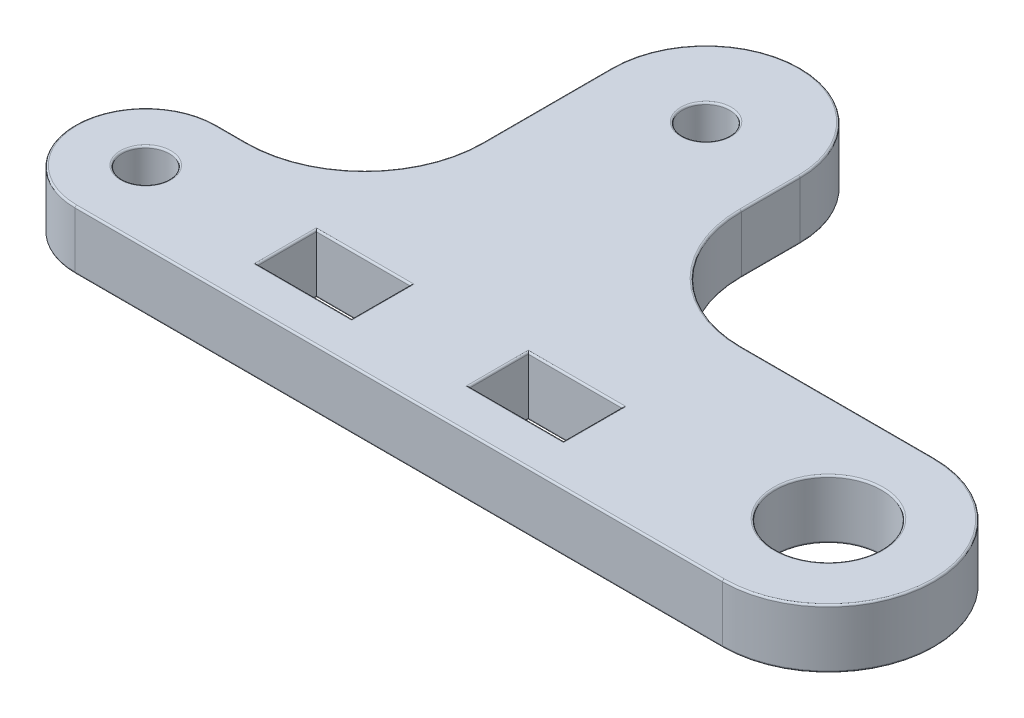
from build123d import *

# Parameters (mm, degrees)
SKETCH2_R           = 2
SKETCH2_R_2         = 4.5
SKETCH2_W           = 8
SKETCH2_H           = 5
BOSS_EXTRUDE1_DEPTH = 2.5
FILLET1_R           = 0.15


with BuildPart() as part:
    # Sketch2 → Boss-Extrude1 (new body, symmetric)
    with BuildSketch(Plane(origin=(0, 0, 0), x_dir=(1, 0, 0), z_dir=(0, 1, 0))):
        with BuildLine():
            Line((-27.5, 0), (27.5, 0))
            ThreePointArc((27.5, 0), (36.5, 9), (27.5, 18))
            Line((27.5, 18), (11.1, 18))
            ThreePointArc((11.1, 18), (4.028932188, 20.928932188), (1.1, 28))
            Line((1.1, 28), (1.1, 33))
            ThreePointArc((1.1, 33), (-6.9, 41), (-14.9, 33))
            Line((-14.9, 33), (-14.9, 22))
            ThreePointArc((-14.9, 22), (-17.828932188, 14.928932188), (-24.9, 12))
            Line((-24.9, 12), (-27.5, 12))
            ThreePointArc((-27.5, 12), (-33.5, 6), (-27.5, 0))
        make_face()
        with Locations((-27.5, 6)):
            Circle(SKETCH2_R, mode=Mode.SUBTRACT)
        with Locations((27.5, 9)):
            Circle(SKETCH2_R_2, mode=Mode.SUBTRACT)
        with Locations((-6.9, 33)):
            Circle(SKETCH2_R, mode=Mode.SUBTRACT)
        with Locations((-11.5, 6)):
            Rectangle(SKETCH2_W, SKETCH2_H, mode=Mode.SUBTRACT)
        with Locations((6.5, 6)):
            Rectangle(SKETCH2_W, SKETCH2_H, mode=Mode.SUBTRACT)
    extrude(amount=BOSS_EXTRUDE1_DEPTH, both=True)

    # Fillet1
    fillet1_edges = [part.edges().sort_by_distance(p)[0] for p in [
        (-26.2, -2.5, -12),
        (-17.828932188, -2.5, -14.928932188),
        (-14.9, -2.5, -27.5),
        (-6.9, -2.5, -41),
        (1.1, -2.5, -30.5),
        (4.028932188, -2.5, -20.928932188),
        (19.3, -2.5, -18),
        (36.5, 2.5, -9),
        (36.5, -2.5, -9),
        (0, -2.5, 0),
        (-33.5, -2.5, -6),
        (19.3, 2.5, -18),
        (4.028932188, 2.5, -20.928932188),
        (1.1, 2.5, -30.5),
        (-29.5, -2.5, -6),
        (-29.5, 2.5, -6),
        (-6.9, 2.5, -41),
        (23, -2.5, -9),
        (23, 2.5, -9),
        (-14.9, 2.5, -27.5),
        (-8.9, -2.5, -33),
        (-8.9, 2.5, -33),
        (-17.828932188, 2.5, -14.928932188),
        (-15.5, -2.5, -6),
        (-11.5, -2.5, -3.5),
        (-26.2, 2.5, -12),
        (-7.5, -2.5, -6),
        (-11.5, -2.5, -8.5),
        (-15.5, 2.5, -6),
        (-11.5, 2.5, -3.5),
        (-7.5, 2.5, -6),
        (-11.5, 2.5, -8.5),
        (-33.5, 2.5, -6),
        (2.5, -2.5, -6),
        (6.5, -2.5, -3.5),
        (10.5, -2.5, -6),
        (6.5, -2.5, -8.5),
        (2.5, 2.5, -6),
        (6.5, 2.5, -3.5),
        (10.5, 2.5, -6),
        (6.5, 2.5, -8.5),
        (0, 2.5, 0),
    ]]
    fillet(fillet1_edges, radius=FILLET1_R)


solid = part.part
